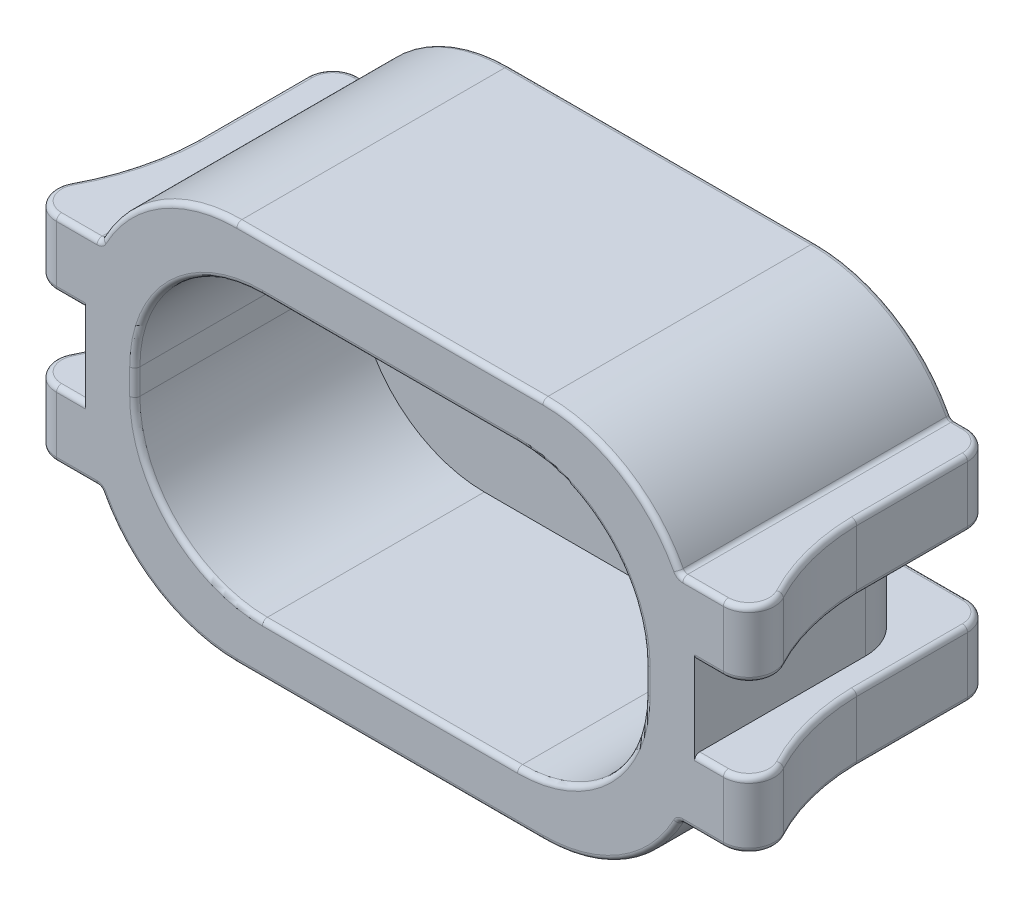
from build123d import *

# Parameters (mm, degrees)
SKETCH1_W               = 12
SKETCH1_H               = 7.5
BOSS_EXTRUDE1_DEPTH     = 5.35
SKETCH2_W               = 10
SKETCH2_H               = 5.5
CUT_EXTRUDE1_DEPTH      = 4.35
FILLET3_R               = 2.5
FILLET1_R               = 3
SKETCH3_W               = 10
SKETCH3_H               = 1.6
CUT_EXTRUDE2_DEPTH      = 2
SKETCH4_OUTSIDE_W       = 17.026
SKETCH4_OUTSIDE_H       = 10.376
CUT_EXTRUDE3_DEPTH      = 1.6
BOSS_EXTRUDE2_START     = -0.290914
SKETCH6_W               = 5.35
SKETCH6_H               = 1.3
BOSS_EXTRUDE2_DEPTH     = 0.790914
BOSS_EXTRUDE8_DEPTH     = 1.3
MIRROR2_START           = -0.290914
MIRROR2_COPY_1_SKETCH_W = 5.35
MIRROR2_COPY_1_SKETCH_H = 1.3
MIRROR2_COPY_1_DEPTH    = 0.790914
MIRROR2_COPY_2_DEPTH    = 1.3
FILLET7_R               = 0.5
FILLET4_R               = 0.1
FILLET6_R               = 0.1
FILLET8_R               = 0.1


with BuildPart() as part:
    # Sketch1 → Boss-Extrude1 (new body)
    with BuildSketch(Plane.XY):
        with Locations((0, -0.8)):
            Rectangle(SKETCH1_W, SKETCH1_H)
    extrude(amount=-BOSS_EXTRUDE1_DEPTH)

    # Sketch2 → Cut-Extrude1 (cut)
    with BuildSketch(Plane.XY):
        with Locations((0, -0.8)):
            Rectangle(SKETCH2_W, SKETCH2_H)
    extrude(amount=-CUT_EXTRUDE1_DEPTH, mode=Mode.SUBTRACT)

    # Fillet3
    fillet3_edges = [part.edges().sort_by_distance(p)[0] for p in [
        (5, -3.55, -2.175),
        (-5, -3.55, -2.175),
        (-5, 1.95, -2.175),
        (5, 1.95, -2.175),
    ]]
    fillet(fillet3_edges, radius=FILLET3_R)

    # Fillet1
    fillet1_edges = [part.edges().sort_by_distance(p)[0] for p in [
        (-6, 2.95, -2.675),
        (6, 2.95, -2.675),
        (6, -4.55, -2.675),
        (-6, -4.55, -2.675),
    ]]
    fillet(fillet1_edges, radius=FILLET1_R)

    # Sketch3 → Cut-Extrude2 (cut, through all)
    with BuildSketch(Plane.XY.offset(-4.35)):
        with Locations((0, -0.8)):
            Rectangle(SKETCH3_W, SKETCH3_H)
    extrude(amount=-CUT_EXTRUDE2_DEPTH, mode=Mode.SUBTRACT)

    # Sketch4 outside → Cut-Extrude3 (cut)
    with BuildSketch(Plane.XZ.offset(1.6)):
        with Locations((0, -2.675)):
            Rectangle(SKETCH4_OUTSIDE_W, SKETCH4_OUTSIDE_H)
        with BuildLine():
            Line((5.97, -3.35), (5.97, 0))
            Line((5.97, 0), (-5.97, 0))
            Line((-5.97, 0), (-5.97, -3.35))
            ThreePointArc((-5.97, -3.35), (-5.677106781, -4.057106781), (-4.97, -4.35))
            Line((-4.97, -4.35), (-4.27, -4.35))
            Line((-4.27, -4.35), (4.27, -4.35))
            Line((4.27, -4.35), (4.97, -4.35))
            ThreePointArc((4.97, -4.35), (5.677106781, -4.057106781), (5.97, -3.35))
        make_face(mode=Mode.SUBTRACT)
    extrude(amount=-CUT_EXTRUDE3_DEPTH, mode=Mode.SUBTRACT)

    # Sketch6 → Boss-Extrude2 (add)
    with BuildSketch(Plane(origin=(5.97, 0, 0), x_dir=(0, 0, -1), z_dir=(1, 0, 0)).offset(BOSS_EXTRUDE2_START)):
        with Locations((2.675, -2.25)):
            Rectangle(SKETCH6_W, SKETCH6_H)
    boss_extrude2 = extrude(amount=BOSS_EXTRUDE2_DEPTH)

    # Sketch11 → Boss-Extrude8 (add)
    with BuildSketch(Plane(origin=(0, -1.6, 0), x_dir=(1, 0, 0), z_dir=(0, 1, 0))):
        with BuildLine():
            Line((6.47, 0), (7.47, 0))
            ThreePointArc((7.47, 0), (6.742851082, 1.252584517), (6.47, 2.675))
            Line((6.47, 2.675), (6.47, 0))
        make_face()
    boss_extrude8 = extrude(amount=-BOSS_EXTRUDE8_DEPTH)

    # Mirror1: Boss-Extrude2, Boss-Extrude8 across plane
    add(boss_extrude2.mirror(Plane.ZX.offset(-0.8)))
    add(boss_extrude8.mirror(Plane.ZX.offset(-0.8)))

    # Mirror2: Boss-Extrude2, Boss-Extrude8 across plane
    add(boss_extrude2.mirror(Plane(origin=(0, 0, 0), x_dir=(0, 0, 1), z_dir=(1, 0, 0))))
    add(boss_extrude8.mirror(Plane(origin=(0, 0, 0), x_dir=(0, 0, 1), z_dir=(1, 0, 0))))

    # Mirror2 copy 1 sketch → Mirror2 copy 1 (add)
    with BuildSketch(Plane(origin=(-5.97, -1.6, 0), x_dir=(0, 0, -1), z_dir=(-1, 0, 0)).offset(MIRROR2_START)):
        with Locations((2.675, -2.25)):
            Rectangle(MIRROR2_COPY_1_SKETCH_W, MIRROR2_COPY_1_SKETCH_H)
    extrude(amount=MIRROR2_COPY_1_DEPTH)

    # Mirror2 copy 2 sketch → Mirror2 copy 2 (add)
    with BuildSketch(Plane(origin=(0, 0, 0), x_dir=(-1, 0, 0), z_dir=(0, -1, 0))):
        with BuildLine():
            Line((6.47, 0), (7.47, 0))
            ThreePointArc((7.47, 0), (6.742851082, 1.252584517), (6.47, 2.675))
            Line((6.47, 2.675), (6.47, 0))
        make_face()
    extrude(amount=-MIRROR2_COPY_2_DEPTH)

    # Fillet7
    fillet7_edges = [part.edges().sort_by_distance(p)[0] for p in [
        (6.47, -2.25, -5.35),
        (7.47, -2.25, 0),
        (6.47, 0.65, -5.35),
        (7.47, 0.65, 0),
        (-6.47, 0.65, -5.35),
        (-7.47, 0.65, 0),
        (-6.47, -2.25, -5.35),
        (-7.47, -2.25, 0),
    ]]
    fillet(fillet7_edges, radius=FILLET7_R)

    # Fillet4
    fillet4_edges = [part.edges().sort_by_distance(p)[0] for p in [
        (5.679086, -2.9, -2.675),
        (5.679086, 1.3, -2.675),
        (-5.679086, 1.3, -2.675),
        (-5.679086, -2.9, -2.675),
    ]]
    fillet(fillet4_edges, radius=FILLET4_R)

    # Fillet6
    fillet6_edges = [part.edges().sort_by_distance(p)[0] for p in [
        (6.25239278, -1.6, 0),
        (6.25239278, 0, 0),
        (6.47, -2.9, -3.7625),
        (6.47, 1.3, -3.7625),
        (-6.47, 1.3, -3.7625),
        (-6.47, -2.9, -3.7625),
        (-6.47, 0, -3.7625),
        (0, 0, -5.35),
        (6.47, 0, -3.7625),
        (6.609106907, 0, -1.675227481),
        (-6.25239278, 0, 0),
        (-6.609106907, 0, -1.675227481),
        (6.323553391, 0, -5.203553391),
        (6.963424389, 0, -0.242572816),
        (-6.963424389, 0, -0.242572816),
        (-6.323553391, 0, -5.203553391),
        (-6.609106907, 1.3, -1.675227481),
        (-6.963424389, 1.3, -0.242572816),
        (-6.323553391, 1.3, -5.203553391),
        (0, -1.6, -5.35),
        (6.609106907, -1.6, -1.675227481),
        (6.47, -1.6, -3.7625),
        (-6.47, -1.6, -3.7625),
        (-6.609106907, -1.6, -1.675227481),
        (-6.25239278, -1.6, 0),
        (6.323553391, -1.6, -5.203553391),
        (6.963424389, -1.6, -0.242572816),
        (-6.963424389, -1.6, -0.242572816),
        (-6.323553391, -1.6, -5.203553391),
        (-6.609106907, -2.9, -1.675227481),
        (-6.963424389, -2.9, -0.242572816),
        (-6.323553391, -2.9, -5.203553391),
        (6.609106907, 1.3, -1.675227481),
        (6.323553391, 1.3, -5.203553391),
        (6.963424389, 1.3, -0.242572816),
        (6.609106907, -2.9, -1.675227481),
        (6.323553391, -2.9, -5.203553391),
        (6.963424389, -2.9, -0.242572816),
        (4.547630864, -4.119988076, -5.35),
        (6.137383656, -2.9, 0),
        (5.854990876, -2.9, -5.35),
        (6.137383656, 1.3, 0),
        (5.854990876, 1.3, -5.35),
        (4.547630864, 2.519988076, 0),
        (-5.854990876, -2.9, -5.35),
        (-6.137383656, -2.9, 0),
        (-4.547630864, -4.119988076, 0),
        (-4.547630864, 2.519988076, -5.35),
        (-5.854990876, 1.3, -5.35),
        (-6.137383656, 1.3, 0),
        (5.688394056, -2.914333731, 0),
        (5.688394056, -2.914333731, -5.35),
        (5.688394056, 1.314333731, 0),
        (5.688394056, 1.314333731, -5.35),
        (-5.688394056, -2.914333731, 0),
        (-5.688394056, -2.914333731, -5.35),
        (-5.688394056, 1.314333731, 0),
        (-5.688394056, 1.314333731, -5.35),
        (0, -4.55, 0),
        (0, 2.95, 0),
        (4.547630864, -4.119988076, 0),
        (-4.547630864, 2.519988076, 0),
        (0, 2.95, -5.35),
        (0, -4.55, -5.35),
        (-4.547630864, -4.119988076, -5.35),
        (4.547630864, 2.519988076, -5.35),
    ]]
    fillet(fillet6_edges, radius=FILLET6_R)

    # Fillet8
    fillet8_edges = [part.edges().sort_by_distance(p)[0] for p in [
        (-5, -0.8, 0),
        (0, 1.95, 0),
        (0, -3.55, 0),
        (5, -0.8, 0),
        (-4.267766953, 1.217766953, 0),
        (-4.267766953, -2.817766953, 0),
        (4.267766953, -2.817766953, 0),
        (4.267766953, 1.217766953, 0),
    ]]
    fillet(fillet8_edges, radius=FILLET8_R)


solid = part.part
